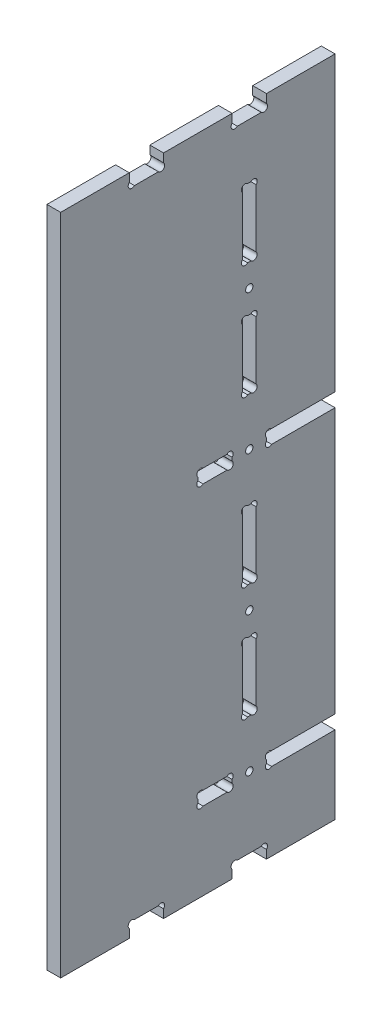
from build123d import *

# Parameters (mm, degrees)
ESQUISSE1_R      = 1.6
EXTRUSION1_DEPTH = 6


with BuildPart() as part:
    # Esquisse1 → Extrusion1 (new body)
    with BuildSketch(Plane(origin=(0, 0, 0), x_dir=(0, 0, -1), z_dir=(1, 0, 0))):
        with BuildLine():
            Line((32.2627417, 6), (42.7372583, 6))
            ThreePointArc((42.7372583, 6), (45, 6), (45, 3.7372583))
            Line((45, 3.7372583), (45, 0))
            Line((45, 0), (75, 0))
            Line((75, 0), (75, 3.7372583))
            ThreePointArc((75, 3.7372583), (75, 6), (77.2627417, 6))
            Line((77.2627417, 6), (87.7372583, 6))
            ThreePointArc((87.7372583, 6), (90, 6), (90, 3.7372583))
            Line((90, 3.7372583), (90, 0))
            Line((90, 0), (120, 0))
            Line((120, 0), (120, 34))
            Line((120, 34), (92.2627417, 34))
            ThreePointArc((92.2627417, 34), (90, 34), (90, 36.2627417))
            Line((90, 36.2627417), (90, 37.7372583))
            ThreePointArc((90, 37.7372583), (90, 40), (92.2627417, 40))
            Line((92.2627417, 40), (120, 40))
            Line((120, 40), (120, 156))
            Line((120, 156), (92.2627417, 156))
            ThreePointArc((92.2627417, 156), (90, 156), (90, 158.2627417))
            Line((90, 158.2627417), (90, 159.7372583))
            ThreePointArc((90, 159.7372583), (90, 162), (92.2627417, 162))
            Line((92.2627417, 162), (120, 162))
            Line((120, 162), (120, 290))
            Line((120, 290), (90, 290))
            Line((90, 290), (90, 286.2627417))
            ThreePointArc((90, 286.2627417), (90, 284), (87.7372583, 284))
            Line((87.7372583, 284), (77.2627417, 284))
            ThreePointArc((77.2627417, 284), (75, 284), (75, 286.2627417))
            Line((75, 286.2627417), (75, 290))
            Line((75, 290), (45, 290))
            Line((45, 290), (45, 286.2627417))
            ThreePointArc((45, 286.2627417), (45, 284), (42.7372583, 284))
            Line((42.7372583, 284), (32.2627417, 284))
            ThreePointArc((32.2627417, 284), (30, 284), (30, 286.2627417))
            Line((30, 286.2627417), (30, 290))
            Line((30, 290), (0, 290))
            Line((0, 290), (0, 0))
            Line((0, 0), (30, 0))
            Line((30, 0), (30, 3.7372583))
            ThreePointArc((30, 3.7372583), (30, 6), (32.2627417, 6))
        make_face()
        with Locations((82.5, 37)):
            Circle(ESQUISSE1_R, mode=Mode.SUBTRACT)
        with Locations(Location((82.5, 159, 0), (0, 0, 180))):  # turned: the seam where the file's is
            Circle(ESQUISSE1_R, mode=Mode.SUBTRACT)
        with Locations((82.5, 98)):
            Circle(ESQUISSE1_R, mode=Mode.SUBTRACT)
        with Locations(Location((82.5, 220, 0), (0, 0, 180))):  # turned: the seam where the file's is
            Circle(ESQUISSE1_R, mode=Mode.SUBTRACT)
        with BuildLine():
            Line((75, 37.7372583), (75, 36.2627417))
            ThreePointArc((75, 36.2627417), (75, 34), (72.7372583, 34))
            Line((72.7372583, 34), (62.2627417, 34))
            ThreePointArc((62.2627417, 34), (60, 34), (60, 36.2627417))
            Line((60, 36.2627417), (60, 37.7372583))
            ThreePointArc((60, 37.7372583), (60, 40), (62.2627417, 40))
            Line((62.2627417, 40), (72.7372583, 40))
            ThreePointArc((72.7372583, 40), (75, 40), (75, 37.7372583))
        make_face(mode=Mode.SUBTRACT)
        with BuildLine():
            Line((60, 158.2627417), (60, 159.7372583))
            ThreePointArc((60, 159.7372583), (60, 162), (62.2627417, 162))
            Line((62.2627417, 162), (72.7372583, 162))
            ThreePointArc((72.7372583, 162), (75, 162), (75, 159.7372583))
            Line((75, 159.7372583), (75, 158.2627417))
            ThreePointArc((75, 158.2627417), (75, 156), (72.7372583, 156))
            Line((72.7372583, 156), (62.2627417, 156))
            ThreePointArc((62.2627417, 156), (60, 156), (60, 158.2627417))
        make_face(mode=Mode.SUBTRACT)
        with BuildLine():
            Line((83.2372583, 138), (81.7627417, 138))
            ThreePointArc((81.7627417, 138), (79.5, 138), (79.5, 135.7372583))
            Line((79.5, 135.7372583), (79.5, 110.2627417))
            ThreePointArc((79.5, 110.2627417), (79.5, 108), (81.7627417, 108))
            Line((81.7627417, 108), (83.2372583, 108))
            ThreePointArc((83.2372583, 108), (85.5, 108), (85.5, 110.2627417))
            Line((85.5, 110.2627417), (85.5, 135.7372583))
            ThreePointArc((85.5, 135.7372583), (85.5, 138), (83.2372583, 138))
        make_face(mode=Mode.SUBTRACT)
        with BuildLine():
            Line((83.2372583, 58), (81.7627417, 58))
            ThreePointArc((81.7627417, 58), (79.5, 58), (79.5, 60.2627417))
            Line((79.5, 60.2627417), (79.5, 85.7372583))
            ThreePointArc((79.5, 85.7372583), (79.5, 88), (81.7627417, 88))
            Line((81.7627417, 88), (83.2372583, 88))
            ThreePointArc((83.2372583, 88), (85.5, 88), (85.5, 85.7372583))
            Line((85.5, 85.7372583), (85.5, 60.2627417))
            ThreePointArc((85.5, 60.2627417), (85.5, 58), (83.2372583, 58))
        make_face(mode=Mode.SUBTRACT)
        with BuildLine():
            Line((85.5, 257.7372583), (85.5, 232.2627417))
            ThreePointArc((85.5, 232.2627417), (85.5, 230), (83.2372583, 230))
            Line((83.2372583, 230), (81.7627417, 230))
            ThreePointArc((81.7627417, 230), (79.5, 230), (79.5, 232.2627417))
            Line((79.5, 232.2627417), (79.5, 257.7372583))
            ThreePointArc((79.5, 257.7372583), (79.5, 260), (81.7627417, 260))
            Line((81.7627417, 260), (83.2372583, 260))
            ThreePointArc((83.2372583, 260), (85.5, 260), (85.5, 257.7372583))
        make_face(mode=Mode.SUBTRACT)
        with BuildLine():
            Line((83.2372583, 210), (81.7627417, 210))
            ThreePointArc((81.7627417, 210), (79.5, 210), (79.5, 207.7372583))
            Line((79.5, 207.7372583), (79.5, 182.2627417))
            ThreePointArc((79.5, 182.2627417), (79.5, 180), (81.7627417, 180))
            Line((81.7627417, 180), (83.2372583, 180))
            ThreePointArc((83.2372583, 180), (85.5, 180), (85.5, 182.2627417))
            Line((85.5, 182.2627417), (85.5, 207.7372583))
            ThreePointArc((85.5, 207.7372583), (85.5, 210), (83.2372583, 210))
        make_face(mode=Mode.SUBTRACT)
    extrude(amount=EXTRUSION1_DEPTH)


solid = part.part
